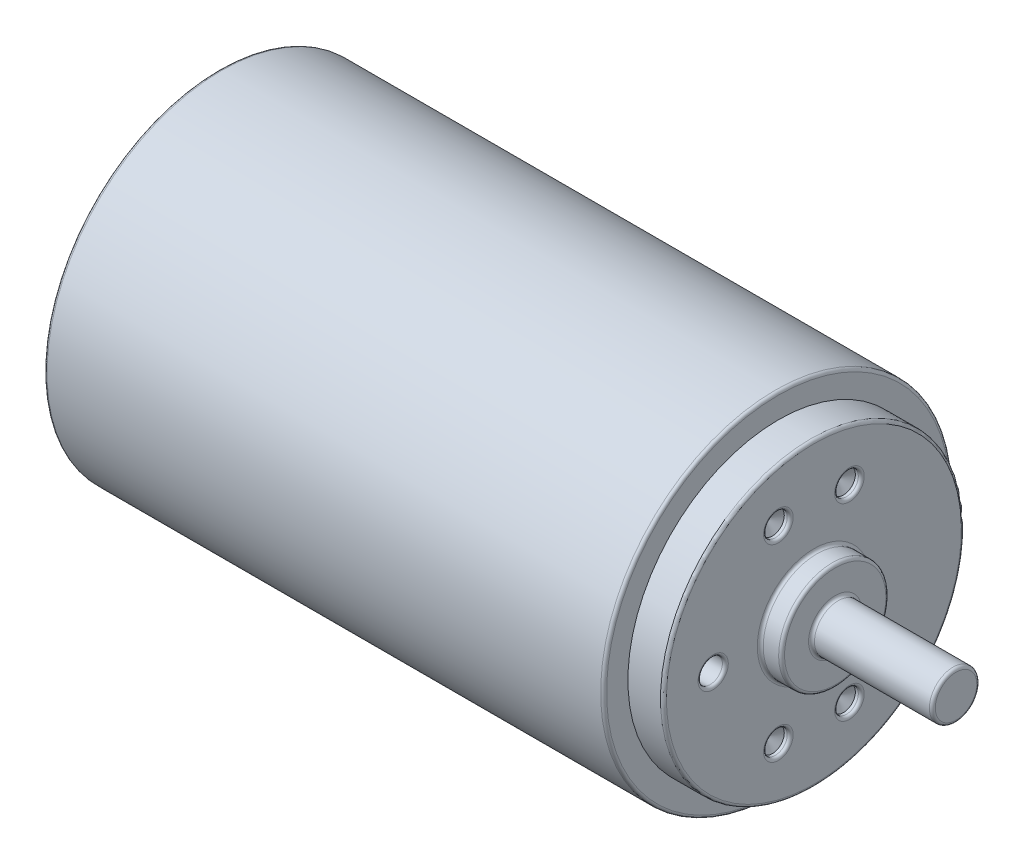
from build123d import *

# Parameters (mm, degrees)
F_4_0_4_DURCHMESSER_BOHRUNG1_D       = 4
F_4_0_4_DURCHMESSER_BOHRUNG1_DEPTH   = 1
F_4_0_4_DURCHMESSER_BOHRUNG1_TIP     = 1.201721238
F_4_1_4_1_DURCHMESSER_BOHRUNG1_D     = 4.1
F_4_1_4_1_DURCHMESSER_BOHRUNG1_DEPTH = 11.5
F_4_1_4_1_DURCHMESSER_BOHRUNG1_TIP   = 1.231764269
VERRUNDUNG1_R                        = 0.5


with BuildPart() as part:
    # Skizze1 → Rotation1 (revolve)
    with BuildSketch(Plane.XY):
        Polygon((-21.65112042, 29.5), (72.808848027, 29.5), (72.808848027, 25.397565661), (78.808848027, 25.397565661), (78.808848027, 9.053899077), (82.408848027, 9.053899077), (82.408848027, 4), (87.880820833, 4), (102.808848027, 4), (102.808848027, 0), (0, 0), (-39.191151973, 0), (-39.191151973, 4), (-30.191151973, 4), (-24.191151973, 5.693354369), (-24.191151973, 22.949681802), (-21.65112042, 22.949681802), align=None)
    revolve(axis=Axis((0, 0, 0), (-1, 0, 0)))

    # Ø4.0 (4) Durchmesser Bohrung1
    with Locations(Plane(origin=(78.808848027, 0, 0), x_dir=(0, 0, -1), z_dir=(1, 0, 0))):
        with Locations((-6, 15.905973721), (6, 15.905973721), (-6, -15.905973721), (6, -15.905973721)):
            Hole(F_4_0_4_DURCHMESSER_BOHRUNG1_D / 2, depth=F_4_0_4_DURCHMESSER_BOHRUNG1_DEPTH)
            with Locations((0, 0, -(F_4_0_4_DURCHMESSER_BOHRUNG1_DEPTH + F_4_0_4_DURCHMESSER_BOHRUNG1_TIP / 2))):  # 118° drill point
                Cone(0, F_4_0_4_DURCHMESSER_BOHRUNG1_D / 2, F_4_0_4_DURCHMESSER_BOHRUNG1_TIP, mode=Mode.SUBTRACT)

    # Ø4.1 (4.1) Durchmesser Bohrung1
    with Locations(Plane(origin=(78.808848027, 0, 0), x_dir=(0, 0, -1), z_dir=(1, 0, 0))):
        with Locations((-17, 0)):
            Hole(F_4_1_4_1_DURCHMESSER_BOHRUNG1_D / 2, depth=F_4_1_4_1_DURCHMESSER_BOHRUNG1_DEPTH)
            with Locations((0, 0, -(F_4_1_4_1_DURCHMESSER_BOHRUNG1_DEPTH + F_4_1_4_1_DURCHMESSER_BOHRUNG1_TIP / 2))):  # 118° drill point
                Cone(0, F_4_1_4_1_DURCHMESSER_BOHRUNG1_D / 2, F_4_1_4_1_DURCHMESSER_BOHRUNG1_TIP, mode=Mode.SUBTRACT)

    # Verrundung1
    verrundung1_edges = [part.edges().sort_by_distance(p)[0] for p in [
        (-21.65112042, -29.5, 0),
        (72.808848027, -29.5, 0),
        (78.808848027, -25.397565661, 0),
        (78.808848027, -9.053899077, 0),
        (82.408848027, -9.053899077, 0),
        (82.408848027, -4, 0),
        (102.808848027, -4, 0),
        (-39.191151973, -4, 0),
        (-24.191151973, -22.949681802, 0),
        (-21.65112042, -22.949681802, 0),
        (78.808848027, -15.905973721, -8),
        (78.808848027, -15.905973721, 4),
        (78.808848027, 15.905973721, -8),
        (78.808848027, 15.905973721, 4),
        (78.808848027, 0, 14.95),
    ]]
    fillet(verrundung1_edges, radius=VERRUNDUNG1_R)


solid = part.part
